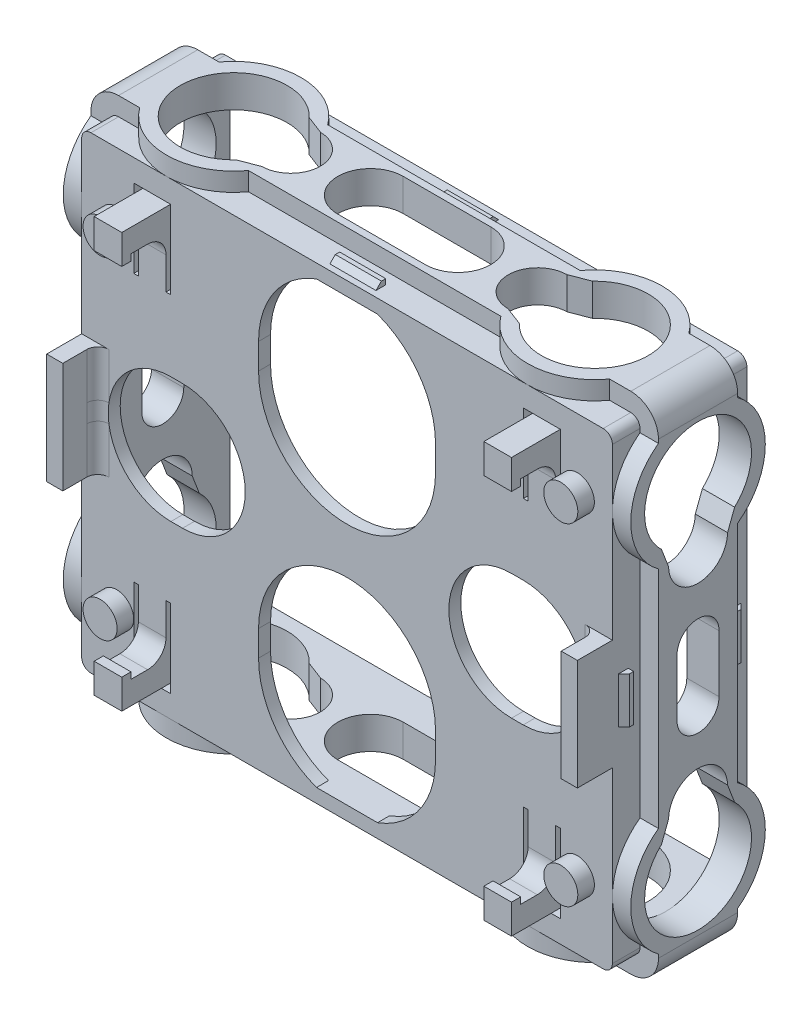
from build123d import *

# Parameters (mm, degrees)
SKETCH_2_W          = 61.6
SKETCH_2_H          = 54.8
EXTRUDE_1_DEPTH     = 1.5
SKETCH_2_4_R        = 1.849118688
EXTRUDE_3_DEPTH     = 3.3
SKETCH_6_W          = 14.6
SKETCH_6_H          = 54.8
EXTRUDE_4_DEPTH     = 3.5
EXTRUDE_START       = -3.5
SKETCH_9_W          = 14.6
SKETCH_9_H          = 54.8
EXTRUDE_6_DEPTH     = 3.5
SKETCH_10_W         = 61.6
SKETCH_10_H         = 14.6
EXTRUDE_7_DEPTH     = 3.5
SKETCH_11_W         = 61.6
SKETCH_11_H         = 14.6
EXTRUDE_8_DEPTH     = 3.5
FILLET_1_R          = 3
CUT_EXTRUDE_1_DEPTH = 3
CUT_EXTRUDE_2_DEPTH = 3
EXTRUDE_9_DEPTH     = 2
EXTRUDE_10_DEPTH    = 2
EXTRUDE_11_DEPTH    = 2
EXTRUDE_12_DEPTH    = 2
EXTRUDE_13_DEPTH    = 2.5
EXTRUDE_14_DEPTH    = 2.5
SKETCH_28_W         = 1.75
SKETCH_28_H         = 12
SKETCH_28_W_2       = 3
SKETCH_28_H_2       = 2.5
EXTRUDE_15_DEPTH    = 3.8
SKETCH_29_W         = 3
SKETCH_29_H         = 3.2
EXTRUDE_16_DEPTH    = 1
CUT_EXTRUDE_4_DEPTH = 1.5
CUT_EXTRUDE_5_DEPTH = 0.2
FILLET_2_R          = 2
FILLET_3_R          = 1.2


with BuildPart() as part:
    # ｽｹｯﾁ2 → ﾎﾞｽ - 押し出し1 (new body)
    with BuildSketch(Plane.XY):
        with Locations((27, 20)):
            Rectangle(SKETCH_2_W, SKETCH_2_H)
        with BuildLine():
            Line((17.396467493, 32.098090349), (17.396467493, 34.884847493))
            ThreePointArc((17.396467493, 34.884847493), (27, 44.48838), (36.603532507, 34.884847493))
            Line((36.603532507, 34.884847493), (36.603532507, 32.098090349))
            ThreePointArc((36.603532507, 32.098090349), (27, 22.494557841), (17.396467493, 32.098090349))
        make_face(mode=Mode.SUBTRACT)
        with BuildLine():
            Line((17.396467493, 7.901909651), (17.396467493, 5.115152507))
            ThreePointArc((17.396467493, 5.115152507), (27, -4.48838), (36.603532507, 5.115152507))
            Line((36.603532507, 5.115152507), (36.603532507, 7.901909651))
            ThreePointArc((36.603532507, 7.901909651), (27, 17.505442159), (17.396467493, 7.901909651))
        make_face(mode=Mode.SUBTRACT)
        with BuildLine():
            Line((46.11976018, 13.198097812), (44.853626262, 13.198097812))
            ThreePointArc((44.853626262, 13.198097812), (38.051724073, 20), (44.853626262, 26.801902188))
            Line((44.853626262, 26.801902188), (46.11976018, 26.801902188))
            ThreePointArc((46.11976018, 26.801902188), (52.921662369, 20), (46.11976018, 13.198097812))
        make_face(mode=Mode.SUBTRACT)
        with BuildLine():
            Line((7.88023982, 13.198097812), (9.146373738, 13.198097812))
            ThreePointArc((9.146373738, 13.198097812), (15.948275927, 20), (9.146373738, 26.801902188))
            Line((9.146373738, 26.801902188), (7.88023982, 26.801902188))
            ThreePointArc((7.88023982, 26.801902188), (1.078337631, 20), (7.88023982, 13.198097812))
        make_face(mode=Mode.SUBTRACT)
    extrude(amount=EXTRUDE_1_DEPTH)

    # ｽｹｯﾁ2<4> → ﾎﾞｽ - 押し出し3 (add)
    with BuildSketch(Plane.XY):
        with Locations((2, 38)):
            Circle(SKETCH_2_4_R)
        with Locations((2, 2)):
            Circle(SKETCH_2_4_R)
        with Locations((52, 2)):
            Circle(SKETCH_2_4_R)
        with Locations((52, 38)):
            Circle(SKETCH_2_4_R)
    extrude(amount=EXTRUDE_3_DEPTH)

    # ｽｹｯﾁ6 → ﾎﾞｽ - 押し出し4 (add)
    with BuildSketch(Plane.ZY.offset(3.8)):
        with Locations((-5.8, 20)):
            Rectangle(SKETCH_6_W, SKETCH_6_H)
        with BuildLine():
            Line((-3.521492008, 23.1), (-3.521492008, 16.9))
            ThreePointArc((-3.521492008, 16.9), (-5.8, 14.621492008), (-8.078507992, 16.9))
            Line((-8.078507992, 16.9), (-8.078507992, 23.1))
            ThreePointArc((-8.078507992, 23.1), (-5.8, 25.378507992), (-3.521492008, 23.1))
        make_face(mode=Mode.SUBTRACT)
        with BuildLine():
            Line((-9.770178394, 33.871799021), (-8.999779069, 31.862398009))
            ThreePointArc((-8.999779069, 31.862398009), (-5.8, 28.7), (-2.600220931, 31.862398009))
            Line((-2.600220931, 31.862398009), (-1.829821606, 33.871799021))
            ThreePointArc((-1.829821606, 33.871799021), (-5.8, 43.9), (-9.770178394, 33.871799021))
        make_face(mode=Mode.SUBTRACT)
        with BuildLine():
            Line((-2.600220931, 8.137601991), (-1.829821606, 6.128200979))
            ThreePointArc((-1.829821606, 6.128200979), (-5.8, -3.9), (-9.770178394, 6.128200979))
            Line((-9.770178394, 6.128200979), (-8.999779069, 8.137601991))
            ThreePointArc((-8.999779069, 8.137601991), (-5.8, 11.3), (-2.600220931, 8.137601991))
        make_face(mode=Mode.SUBTRACT)
    extrude(amount=-EXTRUDE_4_DEPTH)

    # ｽｹｯﾁ9 → ﾎﾞｽ - 押し出し6 (add)
    with BuildSketch(Plane(origin=(57.8, 0, 0), x_dir=(0, 0, -1), z_dir=(1, 0, 0)).offset(EXTRUDE_START)):
        with Locations((5.8, 20)):
            Rectangle(SKETCH_9_W, SKETCH_9_H)
        with BuildLine():
            Line((8.999779069, 31.862398009), (9.770178394, 33.871799021))
            ThreePointArc((9.770178394, 33.871799021), (5.8, 43.9), (1.829821606, 33.871799021))
            Line((1.829821606, 33.871799021), (2.600220931, 31.862398009))
            ThreePointArc((2.600220931, 31.862398009), (5.8, 28.7), (8.999779069, 31.862398009))
        make_face(mode=Mode.SUBTRACT)
        with BuildLine():
            Line((2.600220931, 8.137601991), (1.829821606, 6.128200979))
            ThreePointArc((1.829821606, 6.128200979), (5.8, -3.9), (9.770178394, 6.128200979))
            Line((9.770178394, 6.128200979), (8.999779069, 8.137601991))
            ThreePointArc((8.999779069, 8.137601991), (5.8, 11.3), (2.600220931, 8.137601991))
        make_face(mode=Mode.SUBTRACT)
        with BuildLine():
            Line((3.521492008, 23.1), (3.521492008, 16.9))
            ThreePointArc((3.521492008, 16.9), (5.8, 14.621492008), (8.078507992, 16.9))
            Line((8.078507992, 16.9), (8.078507992, 23.1))
            ThreePointArc((8.078507992, 23.1), (5.8, 25.378507992), (3.521492008, 23.1))
        make_face(mode=Mode.SUBTRACT)
    extrude(amount=EXTRUDE_6_DEPTH)

    # ｽｹｯﾁ10 → ﾎﾞｽ - 押し出し7 (add)
    with BuildSketch(Plane.XZ.offset(7.4)):
        with Locations((27, -5.8)):
            Rectangle(SKETCH_10_W, SKETCH_10_H)
        with BuildLine():
            Line((22.25, -2.25), (31.75, -2.25))
            ThreePointArc((31.75, -2.25), (35.3, -5.8), (31.75, -9.35))
            Line((31.75, -9.35), (22.25, -9.35))
            ThreePointArc((22.25, -9.35), (18.7, -5.8), (22.25, -2.25))
        make_face(mode=Mode.SUBTRACT)
        with BuildLine():
            Line((11.628200979, -9.770178394), (13.637601991, -8.999779069))
            ThreePointArc((13.637601991, -8.999779069), (16.8, -5.8), (13.637601991, -2.600220931))
            Line((13.637601991, -2.600220931), (11.628200979, -1.829821606))
            ThreePointArc((11.628200979, -1.829821606), (1.6, -5.8), (11.628200979, -9.770178394))
        make_face(mode=Mode.SUBTRACT)
        with BuildLine():
            Line((40.362398009, -2.600220931), (42.371799021, -1.829821606))
            ThreePointArc((42.371799021, -1.829821606), (52.4, -5.8), (42.371799021, -9.770178394))
            Line((42.371799021, -9.770178394), (40.362398009, -8.999779069))
            ThreePointArc((40.362398009, -8.999779069), (37.2, -5.8), (40.362398009, -2.600220931))
        make_face(mode=Mode.SUBTRACT)
    extrude(amount=-EXTRUDE_7_DEPTH)

    # ｽｹｯﾁ11 → ﾎﾞｽ - 押し出し8 (add)
    with BuildSketch(Plane(origin=(0, 47.4, 0), x_dir=(1, 0, 0), z_dir=(0, 1, 0))):
        with Locations((27, 5.8)):
            Rectangle(SKETCH_11_W, SKETCH_11_H)
        with BuildLine():
            Line((40.362398009, 2.600220931), (42.371799021, 1.829821606))
            ThreePointArc((42.371799021, 1.829821606), (52.4, 5.8), (42.371799021, 9.770178394))
            Line((42.371799021, 9.770178394), (40.362398009, 8.999779069))
            ThreePointArc((40.362398009, 8.999779069), (37.2, 5.8), (40.362398009, 2.600220931))
        make_face(mode=Mode.SUBTRACT)
        with BuildLine():
            Line((13.637601991, 8.999779069), (11.628200979, 9.770178394))
            ThreePointArc((11.628200979, 9.770178394), (1.6, 5.8), (11.628200979, 1.829821606))
            Line((11.628200979, 1.829821606), (13.637601991, 2.600220931))
            ThreePointArc((13.637601991, 2.600220931), (16.8, 5.8), (13.637601991, 8.999779069))
        make_face(mode=Mode.SUBTRACT)
        with BuildLine():
            Line((22.25, 2.25), (31.75, 2.25))
            ThreePointArc((31.75, 2.25), (35.3, 5.8), (31.75, 9.35))
            Line((31.75, 9.35), (22.25, 9.35))
            ThreePointArc((22.25, 9.35), (18.7, 5.8), (22.25, 2.25))
        make_face(mode=Mode.SUBTRACT)
    extrude(amount=-EXTRUDE_8_DEPTH)

    # ﾌｨﾚｯﾄ1
    fillet_1_edges = [part.edges().sort_by_distance(p)[0] for p in [
        (57.8, 47.4, -5.8),
        (-3.8, 47.4, -5.8),
        (-3.8, -7.4, -5.8),
        (57.8, -7.4, -5.8),
    ]]
    fillet(fillet_1_edges, radius=FILLET_1_R)

    # ｽｹｯﾁ12 → ｶｯﾄ - 押し出し1 (cut)
    with BuildSketch(Plane(origin=(0, 0, -13.1), x_dir=(-1, 0, 0), z_dir=(0, 0, -1))):
        with BuildLine():
            Line((-54.8, -7.4), (0.8, -7.4))
            ThreePointArc((0.8, -7.4), (2.921320344, -6.521320344), (3.8, -4.4))
            Line((3.8, -4.4), (3.8, 44.4))
            ThreePointArc((3.8, 44.4), (2.921320344, 46.521320344), (0.8, 47.4))
            Line((0.8, 47.4), (-54.8, 47.4))
            ThreePointArc((-54.8, 47.4), (-56.921320344, 46.521320344), (-57.8, 44.4))
            Line((-57.8, 44.4), (-57.8, -4.4))
            ThreePointArc((-57.8, -4.4), (-56.921320344, -6.521320344), (-54.8, -7.4))
        make_face()
        with BuildLine():
            Line((-55.8, 44.4), (-55.8, -4.4))
            ThreePointArc((-55.8, -4.4), (-55.507106781, -5.107106781), (-54.8, -5.4))
            Line((-54.8, -5.4), (0.8, -5.4))
            ThreePointArc((0.8, -5.4), (1.507106781, -5.107106781), (1.8, -4.4))
            Line((1.8, -4.4), (1.8, 44.4))
            ThreePointArc((1.8, 44.4), (1.507106781, 45.107106781), (0.8, 45.4))
            Line((0.8, 45.4), (-54.8, 45.4))
            ThreePointArc((-54.8, 45.4), (-55.507106781, 45.107106781), (-55.8, 44.4))
        make_face(mode=Mode.SUBTRACT)
    extrude(amount=-CUT_EXTRUDE_1_DEPTH, mode=Mode.SUBTRACT)

    # ｽｹｯﾁ22 → ｶｯﾄ - 押し出し2 (cut)
    with BuildSketch(Plane.XY.offset(1.5)):
        with BuildLine():
            Line((-3.8, 44.4), (-3.8, -4.4))
            ThreePointArc((-3.8, -4.4), (-2.921320344, -6.521320344), (-0.8, -7.4))
            Line((-0.8, -7.4), (54.8, -7.4))
            ThreePointArc((54.8, -7.4), (56.921320344, -6.521320344), (57.8, -4.4))
            Line((57.8, -4.4), (57.8, 44.4))
            ThreePointArc((57.8, 44.4), (56.921320344, 46.521320344), (54.8, 47.4))
            Line((54.8, 47.4), (-0.8, 47.4))
            ThreePointArc((-0.8, 47.4), (-2.921320344, 46.521320344), (-3.8, 44.4))
        make_face()
        with BuildLine():
            Line((-1.8, 44.4), (-1.8, -4.4))
            ThreePointArc((-1.8, -4.4), (-1.507106781, -5.107106781), (-0.8, -5.4))
            Line((-0.8, -5.4), (54.8, -5.4))
            ThreePointArc((54.8, -5.4), (55.507106781, -5.107106781), (55.8, -4.4))
            Line((55.8, -4.4), (55.8, 44.4))
            ThreePointArc((55.8, 44.4), (55.507106781, 45.107106781), (54.8, 45.4))
            Line((54.8, 45.4), (-0.8, 45.4))
            ThreePointArc((-0.8, 45.4), (-1.507106781, 45.107106781), (-1.8, 44.4))
        make_face(mode=Mode.SUBTRACT)
    extrude(amount=-CUT_EXTRUDE_2_DEPTH, mode=Mode.SUBTRACT)

    # ｽｹｯﾁ21 → ﾎﾞｽ - 押し出し9 (add)
    with BuildSketch(Plane.XZ.offset(7.4)):
        with BuildLine():
            Line((1.500847518, -10.1), (3.507699909, -10.1))
            ThreePointArc((3.507699909, -10.1), (7.4, -11.6), (11.292300091, -10.1))
            Line((11.292300091, -10.1), (13.299152482, -10.1))
            ThreePointArc((13.299152482, -10.1), (7.4, -13.1), (1.500847518, -10.1))
        make_face()
        with BuildLine():
            Line((11.292300091, -1.5), (13.299152482, -1.5))
            ThreePointArc((13.299152482, -1.5), (7.4, 1.5), (1.500847518, -1.5))
            Line((1.500847518, -1.5), (3.507699909, -1.5))
            ThreePointArc((3.507699909, -1.5), (7.4, 0), (11.292300091, -1.5))
        make_face()
        with BuildLine():
            Line((42.707699909, -10.1), (40.700847518, -10.1))
            ThreePointArc((40.700847518, -10.1), (46.6, -13.1), (52.499152482, -10.1))
            Line((52.499152482, -10.1), (50.492300091, -10.1))
            ThreePointArc((50.492300091, -10.1), (46.6, -11.6), (42.707699909, -10.1))
        make_face()
        with BuildLine():
            Line((52.499152482, -1.5), (50.492300091, -1.5))
            ThreePointArc((50.492300091, -1.5), (46.6, 0), (42.707699909, -1.5))
            Line((42.707699909, -1.5), (40.700847518, -1.5))
            ThreePointArc((40.700847518, -1.5), (46.6, 1.5), (52.499152482, -1.5))
        make_face()
    extrude(amount=-EXTRUDE_9_DEPTH)

    # ｽｹｯﾁ23 → ﾎﾞｽ - 押し出し10 (add)
    with BuildSketch(Plane(origin=(0, 47.4, 0), x_dir=(1, 0, 0), z_dir=(0, 1, 0))):
        with BuildLine():
            Line((1.500847518, 10.1), (3.507699909, 10.1))
            ThreePointArc((3.507699909, 10.1), (7.4, 11.6), (11.292300091, 10.1))
            Line((11.292300091, 10.1), (13.299152482, 10.1))
            ThreePointArc((13.299152482, 10.1), (7.4, 13.1), (1.500847518, 10.1))
        make_face()
        with BuildLine():
            Line((52.499152482, 1.5), (50.492300091, 1.5))
            ThreePointArc((50.492300091, 1.5), (46.6, 0), (42.707699909, 1.5))
            Line((42.707699909, 1.5), (40.700847518, 1.5))
            ThreePointArc((40.700847518, 1.5), (46.6, -1.5), (52.499152482, 1.5))
        make_face()
        with BuildLine():
            Line((40.700847518, 10.1), (42.707699909, 10.1))
            ThreePointArc((42.707699909, 10.1), (46.6, 11.6), (50.492300091, 10.1))
            Line((50.492300091, 10.1), (52.499152482, 10.1))
            ThreePointArc((52.499152482, 10.1), (46.6, 13.1), (40.700847518, 10.1))
        make_face()
        with BuildLine():
            Line((13.299152482, 1.5), (11.292300091, 1.5))
            ThreePointArc((11.292300091, 1.5), (7.4, 0), (3.507699909, 1.5))
            Line((3.507699909, 1.5), (1.500847518, 1.5))
            ThreePointArc((1.500847518, 1.5), (7.4, -1.5), (13.299152482, 1.5))
        make_face()
    extrude(amount=-EXTRUDE_10_DEPTH)

    # ｽｹｯﾁ24 → ﾎﾞｽ - 押し出し11 (add)
    with BuildSketch(Plane(origin=(57.8, 0, 0), x_dir=(0, 0, -1), z_dir=(1, 0, 0))):
        with BuildLine():
            Line((1.5, 41.992300091), (1.5, 43.999152482))
            ThreePointArc((1.5, 43.999152482), (-1.5, 38.1), (1.5, 32.200847518))
            Line((1.5, 32.200847518), (1.5, 34.207699909))
            ThreePointArc((1.5, 34.207699909), (0, 38.1), (1.5, 41.992300091))
        make_face()
        with BuildLine():
            Line((10.1, 32.200847518), (10.1, 34.207699909))
            ThreePointArc((10.1, 34.207699909), (11.6, 38.1), (10.1, 41.992300091))
            Line((10.1, 41.992300091), (10.1, 43.999152482))
            ThreePointArc((10.1, 43.999152482), (13.1, 38.1), (10.1, 32.200847518))
        make_face()
        with BuildLine():
            Line((10.1, -1.992300091), (10.1, -3.999152482))
            ThreePointArc((10.1, -3.999152482), (13.1, 1.9), (10.1, 7.799152482))
            Line((10.1, 7.799152482), (10.1, 5.792300091))
            ThreePointArc((10.1, 5.792300091), (11.6, 1.9), (10.1, -1.992300091))
        make_face()
        with BuildLine():
            Line((1.5, 7.799152482), (1.5, 5.792300091))
            ThreePointArc((1.5, 5.792300091), (0, 1.9), (1.5, -1.992300091))
            Line((1.5, -1.992300091), (1.5, -3.999152482))
            ThreePointArc((1.5, -3.999152482), (-1.5, 1.9), (1.5, 7.799152482))
        make_face()
    extrude(amount=-EXTRUDE_11_DEPTH)

    # ｽｹｯﾁ25 → ﾎﾞｽ - 押し出し12 (add)
    with BuildSketch(Plane.ZY.offset(3.8)):
        with BuildLine():
            Line((-1.5, 43.999152482), (-1.5, 41.992300091))
            ThreePointArc((-1.5, 41.992300091), (0, 38.1), (-1.5, 34.207699909))
            Line((-1.5, 34.207699909), (-1.5, 32.200847518))
            ThreePointArc((-1.5, 32.200847518), (1.5, 38.1), (-1.5, 43.999152482))
        make_face()
        with BuildLine():
            Line((-1.5, 7.799152482), (-1.5, 5.792300091))
            ThreePointArc((-1.5, 5.792300091), (0, 1.9), (-1.5, -1.992300091))
            Line((-1.5, -1.992300091), (-1.5, -3.999152482))
            ThreePointArc((-1.5, -3.999152482), (1.5, 1.9), (-1.5, 7.799152482))
        make_face()
        with BuildLine():
            Line((-10.1, -3.999152482), (-10.1, -1.992300091))
            ThreePointArc((-10.1, -1.992300091), (-11.6, 1.9), (-10.1, 5.792300091))
            Line((-10.1, 5.792300091), (-10.1, 7.799152482))
            ThreePointArc((-10.1, 7.799152482), (-13.1, 1.9), (-10.1, -3.999152482))
        make_face()
        with BuildLine():
            Line((-10.1, 32.200847518), (-10.1, 34.207699909))
            ThreePointArc((-10.1, 34.207699909), (-11.6, 38.1), (-10.1, 41.992300091))
            Line((-10.1, 41.992300091), (-10.1, 43.999152482))
            ThreePointArc((-10.1, 43.999152482), (-13.1, 38.1), (-10.1, 32.200847518))
        make_face()
    extrude(amount=-EXTRUDE_12_DEPTH)

    # ｽｹｯﾁ26 → ﾎﾞｽ - 押し出し13 (add, symmetric)
    with BuildSketch(Plane(origin=(0, 20, 0), x_dir=(1, 0, 0), z_dir=(0, 1, 0))):
        Polygon((56.388664164, -0.246601917), (56.388664164, 0.223398083), (55.8, 0.223398083), (55.8, -0.835266081), align=None)
        Polygon((55.8, 11.376601917), (56.388664164, 11.376601917), (56.388664164, 11.846601917), (55.8, 12.435266081), align=None)
        Polygon((-2.388664164, 11.846601917), (-2.388664164, 11.376601917), (-1.8, 11.376601917), (-1.8, 12.435266081), align=None)
        Polygon((-1.8, 0.223398083), (-2.388664164, 0.223398083), (-2.388664164, -0.246601917), (-1.8, -0.835266081), align=None)
    extrude(amount=EXTRUDE_13_DEPTH, both=True)

    # ｽｹｯﾁ27 → ﾎﾞｽ - 押し出し14 (add, symmetric)
    with BuildSketch(Plane.ZY.offset(-27)):
        Polygon((0.271335836, 45.988664164), (-0.198664164, 45.988664164), (-0.198664164, 45.4), (0.86, 45.4), align=None)
        Polygon((-11.401335836, 45.4), (-12.46, 45.4), (-11.871335836, 45.988664164), (-11.401335836, 45.988664164), align=None)
        Polygon((-11.401335836, -5.4), (-11.401335836, -5.988664164), (-11.871335836, -5.988664164), (-12.46, -5.4), align=None)
        Polygon((-0.198664164, -5.988664164), (-0.198664164, -5.4), (0.86, -5.4), (0.271335836, -5.988664164), align=None)
    extrude(amount=EXTRUDE_14_DEPTH, both=True)

    # ｽｹｯﾁ28 → ﾎﾞｽ - 押し出し15 (add)
    with BuildSketch(Plane.XY.offset(1.5)):
        with Locations((-0.925, 20)):
            Rectangle(SKETCH_28_W, SKETCH_28_H)
        with Locations((54.925, 20)):
            Rectangle(SKETCH_28_W, SKETCH_28_H)
        with Locations((5.85, 41.25)):
            Rectangle(SKETCH_28_W_2, SKETCH_28_H_2)
        with Locations((5.85, -1.25)):
            Rectangle(SKETCH_28_W_2, SKETCH_28_H_2)
        with Locations((48.15, -1.25)):
            Rectangle(SKETCH_28_W_2, SKETCH_28_H_2)
        with Locations((48.15, 41.25)):
            Rectangle(SKETCH_28_W_2, SKETCH_28_H_2)
    extrude(amount=EXTRUDE_15_DEPTH)

    # ｽｹｯﾁ29 → ﾎﾞｽ - 押し出し16 (add)
    with BuildSketch(Plane.XY.offset(5.3)):
        with Locations((5.85, 40.9)):
            Rectangle(SKETCH_29_W, SKETCH_29_H)
        with Locations((5.85, -0.9)):
            Rectangle(SKETCH_29_W, SKETCH_29_H)
        with Locations((48.15, -0.9)):
            Rectangle(SKETCH_29_W, SKETCH_29_H)
        with Locations((48.15, 40.9)):
            Rectangle(SKETCH_29_W, SKETCH_29_H)
    extrude(amount=EXTRUDE_16_DEPTH)

    # ｽｹｯﾁ30 → ｶｯﾄ - 押し出し4 (cut)
    with BuildSketch(Plane.XY.offset(1.5)):
        Polygon((4.35, 42.5), (4.35, 34.5), (3.85, 34.5), (3.85, 43), (7.85, 43), (7.85, 34.5), (7.35, 34.5), (7.35, 42.5), align=None)
        Polygon((7.35, 5.5), (7.85, 5.5), (7.85, -3), (3.85, -3), (3.85, 5.5), (4.35, 5.5), (4.35, -2.5), (7.35, -2.5), align=None)
        Polygon((49.65, -2.5), (49.65, 5.5), (50.15, 5.5), (50.15, -3), (46.15, -3), (46.15, 5.5), (46.65, 5.5), (46.65, -2.5), align=None)
        Polygon((46.65, 34.5), (46.15, 34.5), (46.15, 43), (50.15, 43), (50.15, 34.5), (49.65, 34.5), (49.65, 42.5), (46.65, 42.5), align=None)
    extrude(amount=-CUT_EXTRUDE_4_DEPTH, mode=Mode.SUBTRACT)

    # ｽｹｯﾁ31 → ｶｯﾄ - 押し出し5 (cut)
    with BuildSketch(Plane(origin=(0, 0, 0), x_dir=(-1, 0, 0), z_dir=(0, 0, -1))):
        with BuildLine():
            Line((0.3, -3.9), (0.3, 1.9))
            Line((0.3, 1.9), (0.3, 38.1))
            Line((0.3, 38.1), (0.3, 43.9))
            Line((0.3, 43.9), (-7.4, 43.9))
            Line((-7.4, 43.9), (-23.690187032, 43.9))
            ThreePointArc((-23.690187032, 43.9), (-19.125556114, 40.382207777), (-17.396467493, 34.884847493))
            Line((-17.396467493, 34.884847493), (-17.396467493, 32.098090349))
            ThreePointArc((-17.396467493, 32.098090349), (-27, 22.494557841), (-36.603532507, 32.098090349))
            Line((-36.603532507, 32.098090349), (-36.603532507, 34.884847493))
            ThreePointArc((-36.603532507, 34.884847493), (-34.874443886, 40.382207777), (-30.309812968, 43.9))
            Line((-30.309812968, 43.9), (-46.6, 43.9))
            Line((-46.6, 43.9), (-54.3, 43.9))
            Line((-54.3, 43.9), (-54.3, 38.1))
            Line((-54.3, 38.1), (-54.3, 1.9))
            Line((-54.3, 1.9), (-54.3, -3.9))
            Line((-54.3, -3.9), (-46.6, -3.9))
            Line((-46.6, -3.9), (-30.309812968, -3.9))
            ThreePointArc((-30.309812968, -3.9), (-34.874443886, -0.382207777), (-36.603532507, 5.115152507))
            Line((-36.603532507, 5.115152507), (-36.603532507, 7.901909651))
            ThreePointArc((-36.603532507, 7.901909651), (-27, 17.505442159), (-17.396467493, 7.901909651))
            Line((-17.396467493, 7.901909651), (-17.396467493, 5.115152507))
            ThreePointArc((-17.396467493, 5.115152507), (-19.125556114, -0.382207777), (-23.690187032, -3.9))
            Line((-23.690187032, -3.9), (-7.4, -3.9))
            Line((-7.4, -3.9), (0.3, -3.9))
        make_face()
    extrude(amount=-CUT_EXTRUDE_5_DEPTH, mode=Mode.SUBTRACT)

    # ﾌｨﾚｯﾄ2
    fillet_2_edges = [part.edges().sort_by_distance(p)[0] for p in [
        (5.85, 40, 1.5),
        (5.85, 0, 1.5),
        (48.15, 0, 1.5),
        (48.15, 40, 1.5),
    ]]
    fillet(fillet_2_edges, radius=FILLET_2_R)

    # ﾌｨﾚｯﾄ3
    fillet_3_edges = [part.edges().sort_by_distance(p)[0] for p in [
        (54.05, 20, 1.5),
        (-0.05, 20, 1.5),
    ]]
    fillet(fillet_3_edges, radius=FILLET_3_R)


solid = part.part
